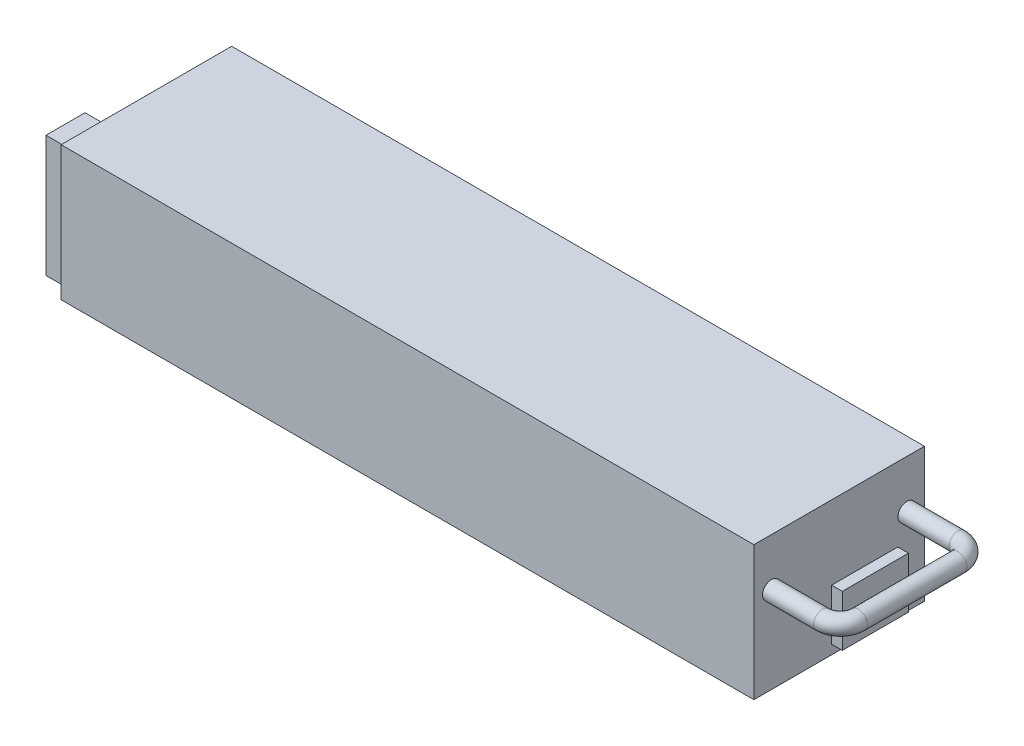
from build123d import *

# Parameters (mm, degrees)
SKETCH1_W           = 325
SKETCH1_H           = 80
BOSS_EXTRUDE1_DEPTH = 63
SKETCH2_R           = 4.2
BOSS_EXTRUDE2_DEPTH = 24
SKETCH3_R           = 4.2
REVOLVE1_ANGLE      = 90
SKETCH4_R           = 4.2
REVOLVE2_ANGLE      = 90
SKETCH5_R           = 4.2
BOSS_EXTRUDE3_DEPTH = 46.7
SKETCH6_W           = 31
SKETCH6_H           = 24
BOSS_EXTRUDE4_DEPTH = 5
SKETCH7_W           = 18.321036957
SKETCH7_H           = 57
BOSS_EXTRUDE5_DEPTH = 10.6
SKETCH8_R           = 1.5
CUT_EXTRUDE1_DEPTH  = 12
SKETCH9_R           = 1.5
CUT_EXTRUDE3_DEPTH  = 12


with BuildPart() as part:
    # Sketch1 → Boss-Extrude1 (new body)
    with BuildSketch(Plane(origin=(0, 0, 0), x_dir=(1, 0, 0), z_dir=(0, 1, 0))):
        with Locations((-162.5, -40)):
            Rectangle(SKETCH1_W, SKETCH1_H)
    extrude(amount=BOSS_EXTRUDE1_DEPTH)

    # Sketch2 → Boss-Extrude2 (add)
    with BuildSketch(Plane(origin=(0, 0, 0), x_dir=(0, 0, -1), z_dir=(1, 0, 0))):
        with Locations((-71.75, 40.5)):
            Circle(SKETCH2_R)
        with Locations((-8.25, 40.5)):
            Circle(SKETCH2_R)
    extrude(amount=BOSS_EXTRUDE2_DEPTH)

    # Sketch3 → Revolve1 (revolve)
    with BuildSketch(Plane(origin=(24, 0, 0), x_dir=(0, 0, -1), z_dir=(1, 0, 0))):
        with Locations((-71.75, 40.5)):
            Circle(SKETCH3_R)
    revolve(axis=Axis((24, 40.5, 63.35), (0, 1, 0)), revolution_arc=REVOLVE1_ANGLE)

    # Sketch4 → Revolve2 (revolve)
    with BuildSketch(Plane(origin=(24, 0, 0), x_dir=(0, 0, -1), z_dir=(1, 0, 0))):
        with Locations((-8.25, 40.5)):
            Circle(SKETCH4_R)
    revolve(axis=Axis((24, 40.5, 16.65), (0, -1, 0)), revolution_arc=REVOLVE2_ANGLE)

    # Sketch5 → Boss-Extrude3 (add)
    with BuildSketch(Plane.XY.offset(16.65)):
        with Locations((32.4, 40.5)):
            Circle(SKETCH5_R)
    extrude(amount=BOSS_EXTRUDE3_DEPTH)

    # Sketch6 → Boss-Extrude4 (add)
    with BuildSketch(Plane(origin=(0, 0, 0), x_dir=(0, 0, -1), z_dir=(1, 0, 0))):
        with Locations((-28, 16.3)):
            Rectangle(SKETCH6_W, SKETCH6_H)
    extrude(amount=BOSS_EXTRUDE4_DEPTH)

    # Sketch7 → Boss-Extrude5 (add)
    with BuildSketch(Plane.ZY.offset(325)):
        with Locations((67.339481522, 31.3)):
            Rectangle(SKETCH7_W, SKETCH7_H)
    extrude(amount=BOSS_EXTRUDE5_DEPTH)

    # Sketch8 → Cut-Extrude1 (cut)
    with BuildSketch(Plane.XZ):
        with Locations((-317, 65)):
            Circle(SKETCH8_R)
        with Locations((-162.5, 74.5)):
            Circle(SKETCH8_R)
        with Locations((-5.25, 55)):
            Circle(SKETCH8_R)
    extrude(amount=-CUT_EXTRUDE1_DEPTH, mode=Mode.SUBTRACT)

    # Sketch9 → Cut-Extrude3 (cut)
    with BuildSketch(Plane(origin=(0, 0, 0), x_dir=(-1, 0, 0), z_dir=(0, 0, -1))):
        with Locations((5.25, 26)):
            Circle(SKETCH9_R)
        with Locations((297, 58)):
            Circle(SKETCH9_R)
    extrude(amount=-CUT_EXTRUDE3_DEPTH, mode=Mode.SUBTRACT)


solid = part.part
